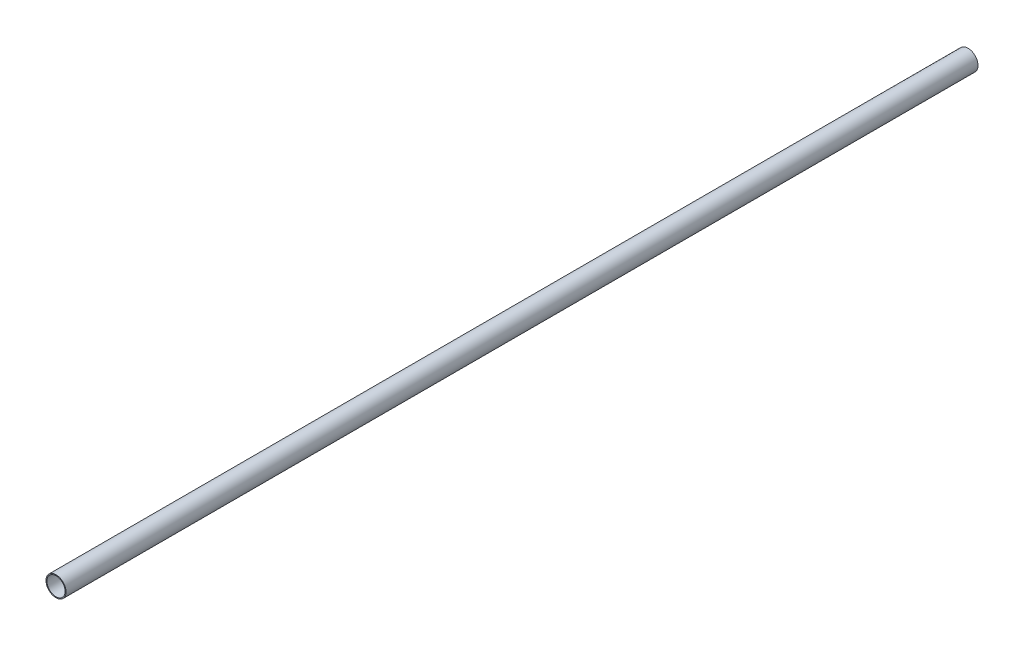
from build123d import *

# Parameters (mm, degrees)
SKETCH1_R           = 11
SKETCH1_R_2         = 10
BOSS_EXTRUDE1_DEPTH = 1000


with BuildPart() as part:
    # Sketch1 → Boss-Extrude1 (new body)
    with BuildSketch(Plane.XY):
        Circle(SKETCH1_R)
        Circle(SKETCH1_R_2, mode=Mode.SUBTRACT)
    extrude(amount=BOSS_EXTRUDE1_DEPTH)


solid = part.part
